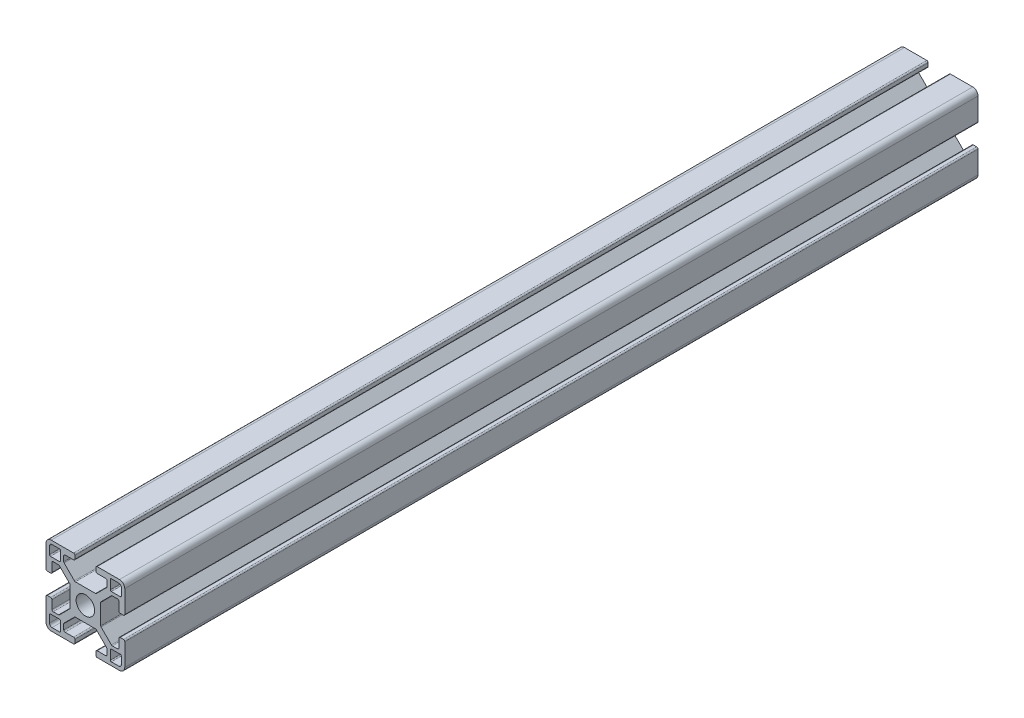
from build123d import *

# Parameters (mm, degrees)
SKETCH1_R           = 3.52998588
BOSS_EXTRUDE1_DEPTH = 162.5


with BuildPart() as part:
    # Sketch1 → Boss-Extrude1 (new body, symmetric)
    with BuildSketch(Plane.XY):
        with BuildLine():
            Line((14.49994, -4), (13.24247465, -4))
            ThreePointArc((13.24247465, -4), (12.88892126, -4.146446609), (12.74247465, -4.5))
            Line((12.74247465, -4.5), (12.74247465, -7.732519321))
            ThreePointArc((12.74247465, -7.732519321), (12.602449697, -8.097296796), (12.242781236, -8.249967))
            Line((12.242781236, -8.249967), (10.260188032, -8.249967))
            ThreePointArc((10.260188032, -8.249967), (10.068847082, -8.211906919), (9.906636056, -8.103520976))
            Line((9.906636056, -8.103520976), (5.981117769, -4.178002689))
            ThreePointArc((5.981117769, -4.178002689), (5.872731827, -4.015791664), (5.834671745, -3.824450713))
            Line((5.834671745, -3.824450713), (5.834671745, -1.01249595))
            Line((5.834671745, -1.01249595), (5.834671745, 0.88749645))
            Line((5.834671745, 0.88749645), (5.834671745, 3.824450713))
            ThreePointArc((5.834671745, 3.824450713), (5.872731827, 4.015791664), (5.981117769, 4.178002689))
            Line((5.981117769, 4.178002689), (9.906636056, 8.103520976))
            ThreePointArc((9.906636056, 8.103520976), (10.068847082, 8.211906919), (10.260188032, 8.249967))
            Line((10.260188032, 8.249967), (12.242781236, 8.249967))
            ThreePointArc((12.242781236, 8.249967), (12.602449697, 8.097296796), (12.74247465, 7.732519321))
            Line((12.74247465, 7.732519321), (12.74247465, 4.5))
            ThreePointArc((12.74247465, 4.5), (12.88892126, 4.146446609), (13.24247465, 4))
            Line((13.24247465, 4), (14.49994, 4))
            ThreePointArc((14.49994, 4), (14.853493391, 4.146446609), (14.99994, 4.5))
            Line((14.99994, 4.5), (14.99994, 12.999948))
            ThreePointArc((14.99994, 12.999948), (14.414155906, 14.414155906), (12.999948, 14.99994))
            Line((12.999948, 14.99994), (4.5, 14.99994))
            ThreePointArc((4.5, 14.99994), (4.146446609, 14.853493391), (4, 14.49994))
            Line((4, 14.49994), (4, 13.24247465))
            ThreePointArc((4, 13.24247465), (4.146446609, 12.88892126), (4.5, 12.74247465))
            Line((4.5, 12.74247465), (7.732519321, 12.74247465))
            ThreePointArc((7.732519321, 12.74247465), (8.097296796, 12.602449697), (8.249967, 12.242781236))
            Line((8.249967, 12.242781236), (8.249967, 10.260188032))
            ThreePointArc((8.249967, 10.260188032), (8.211906919, 10.068847082), (8.103520976, 9.906636056))
            Line((8.103520976, 9.906636056), (4.178002689, 5.981117769))
            ThreePointArc((4.178002689, 5.981117769), (4.015791664, 5.872731827), (3.824450713, 5.834671745))
            Line((3.824450713, 5.834671745), (0.9499962, 5.834671745))
            Line((0.9499962, 5.834671745), (-0.9499962, 5.834671745))
            Line((-0.9499962, 5.834671745), (-3.824450713, 5.834671745))
            ThreePointArc((-3.824450713, 5.834671745), (-4.015791664, 5.872731827), (-4.178002689, 5.981117769))
            Line((-4.178002689, 5.981117769), (-8.103520976, 9.906636056))
            ThreePointArc((-8.103520976, 9.906636056), (-8.211906919, 10.068847082), (-8.249967, 10.260188032))
            Line((-8.249967, 10.260188032), (-8.249967, 12.242781236))
            ThreePointArc((-8.249967, 12.242781236), (-8.097296796, 12.602449697), (-7.732519321, 12.74247465))
            Line((-7.732519321, 12.74247465), (-4.5, 12.74247465))
            ThreePointArc((-4.5, 12.74247465), (-4.146446609, 12.88892126), (-4, 13.24247465))
            Line((-4, 13.24247465), (-4, 14.49994))
            ThreePointArc((-4, 14.49994), (-4.146446609, 14.853493391), (-4.5, 14.99994))
            Line((-4.5, 14.99994), (-12.999948, 14.99994))
            ThreePointArc((-12.999948, 14.99994), (-14.414155906, 14.414155906), (-14.99994, 12.999948))
            Line((-14.99994, 12.999948), (-14.99994, 4.5))
            ThreePointArc((-14.99994, 4.5), (-14.853493391, 4.146446609), (-14.49994, 4))
            Line((-14.49994, 4), (-13.24247465, 4))
            ThreePointArc((-13.24247465, 4), (-12.88892126, 4.146446609), (-12.74247465, 4.5))
            Line((-12.74247465, 4.5), (-12.74247465, 7.732519321))
            ThreePointArc((-12.74247465, 7.732519321), (-12.602449697, 8.097296796), (-12.242781236, 8.249967))
            Line((-12.242781236, 8.249967), (-10.260188032, 8.249967))
            ThreePointArc((-10.260188032, 8.249967), (-10.068847082, 8.211906919), (-9.906636056, 8.103520976))
            Line((-9.906636056, 8.103520976), (-5.981117769, 4.178002689))
            ThreePointArc((-5.981117769, 4.178002689), (-5.872731827, 4.015791664), (-5.834671745, 3.824450713))
            Line((-5.834671745, 3.824450713), (-5.834671745, 0.88749645))
            Line((-5.834671745, 0.88749645), (-5.834671745, -1.01249595))
            Line((-5.834671745, -1.01249595), (-5.834671745, -3.824450713))
            ThreePointArc((-5.834671745, -3.824450713), (-5.872731827, -4.015791664), (-5.981117769, -4.178002689))
            Line((-5.981117769, -4.178002689), (-9.906636056, -8.103520976))
            ThreePointArc((-9.906636056, -8.103520976), (-10.068847082, -8.211906919), (-10.260188032, -8.249967))
            Line((-10.260188032, -8.249967), (-12.242781236, -8.249967))
            ThreePointArc((-12.242781236, -8.249967), (-12.602449697, -8.097296796), (-12.74247465, -7.732519321))
            Line((-12.74247465, -7.732519321), (-12.74247465, -4.5))
            ThreePointArc((-12.74247465, -4.5), (-12.88892126, -4.146446609), (-13.24247465, -4))
            Line((-13.24247465, -4), (-14.49994, -4))
            ThreePointArc((-14.49994, -4), (-14.853493391, -4.146446609), (-14.99994, -4.5))
            Line((-14.99994, -4.5), (-14.99994, -12.999948))
            ThreePointArc((-14.99994, -12.999948), (-14.414155906, -14.414155906), (-12.999948, -14.99994))
            Line((-12.999948, -14.99994), (-4.5, -14.99994))
            ThreePointArc((-4.5, -14.99994), (-4.146446609, -14.853493391), (-4, -14.49994))
            Line((-4, -14.49994), (-4, -13.24247465))
            ThreePointArc((-4, -13.24247465), (-4.146446609, -12.88892126), (-4.5, -12.74247465))
            Line((-4.5, -12.74247465), (-7.732519321, -12.74247465))
            ThreePointArc((-7.732519321, -12.74247465), (-8.097296796, -12.602449697), (-8.249967, -12.242781236))
            Line((-8.249967, -12.242781236), (-8.249967, -10.260188032))
            ThreePointArc((-8.249967, -10.260188032), (-8.211906919, -10.068847082), (-8.103520976, -9.906636056))
            Line((-8.103520976, -9.906636056), (-4.178002689, -5.981117769))
            ThreePointArc((-4.178002689, -5.981117769), (-4.015791664, -5.872731827), (-3.824450713, -5.834671745))
            Line((-3.824450713, -5.834671745), (-0.9499962, -5.834671745))
            Line((-0.9499962, -5.834671745), (0.9499962, -5.834671745))
            Line((0.9499962, -5.834671745), (3.824450713, -5.834671745))
            ThreePointArc((3.824450713, -5.834671745), (4.015791664, -5.872731827), (4.178002689, -5.981117769))
            Line((4.178002689, -5.981117769), (8.103520976, -9.906636056))
            ThreePointArc((8.103520976, -9.906636056), (8.211906919, -10.068847082), (8.249967, -10.260188032))
            Line((8.249967, -10.260188032), (8.249967, -12.242781236))
            ThreePointArc((8.249967, -12.242781236), (8.097296796, -12.602449697), (7.732519321, -12.74247465))
            Line((7.732519321, -12.74247465), (4.5, -12.74247465))
            ThreePointArc((4.5, -12.74247465), (4.146446609, -12.88892126), (4, -13.24247465))
            Line((4, -13.24247465), (4, -14.49994))
            ThreePointArc((4, -14.49994), (4.146446609, -14.853493391), (4.5, -14.99994))
            Line((4.5, -14.99994), (12.999948, -14.99994))
            ThreePointArc((12.999948, -14.99994), (14.414155906, -14.414155906), (14.99994, -12.999948))
            Line((14.99994, -12.999948), (14.99994, -4.5))
            ThreePointArc((14.99994, -4.5), (14.853493391, -4.146446609), (14.49994, -4))
        make_face()
        Circle(SKETCH1_R, mode=Mode.SUBTRACT)
        with BuildLine():
            Line((-12.6999492, -13.6999452), (-9.880960476, -13.6999452))
            ThreePointArc((-9.880960476, -13.6999452), (-9.61155387, -13.58835333), (-9.499962, -13.318946724))
            Line((-9.499962, -13.318946724), (-9.499962, -9.87996048))
            ThreePointArc((-9.499962, -9.87996048), (-9.611260978, -9.611260978), (-9.87996048, -9.499962))
            Line((-9.87996048, -9.499962), (-13.318946724, -9.499962))
            ThreePointArc((-13.318946724, -9.499962), (-13.58835333, -9.61155387), (-13.6999452, -9.880960476))
            Line((-13.6999452, -9.880960476), (-13.6999452, -12.6999492))
            ThreePointArc((-13.6999452, -12.6999492), (-13.407053153, -13.407053153), (-12.6999492, -13.6999452))
        make_face(mode=Mode.SUBTRACT)
        with BuildLine():
            Line((13.6999452, -12.6999492), (13.6999452, -9.880960476))
            ThreePointArc((13.6999452, -9.880960476), (13.58835333, -9.61155387), (13.318946724, -9.499962))
            Line((13.318946724, -9.499962), (9.87996048, -9.499962))
            ThreePointArc((9.87996048, -9.499962), (9.611260978, -9.611260978), (9.499962, -9.87996048))
            Line((9.499962, -9.87996048), (9.499962, -13.318946724))
            ThreePointArc((9.499962, -13.318946724), (9.61155387, -13.58835333), (9.880960476, -13.6999452))
            Line((9.880960476, -13.6999452), (12.6999492, -13.6999452))
            ThreePointArc((12.6999492, -13.6999452), (13.407053153, -13.407053153), (13.6999452, -12.6999492))
        make_face(mode=Mode.SUBTRACT)
        with BuildLine():
            Line((9.87996048, 9.499962), (13.318946724, 9.499962))
            ThreePointArc((13.318946724, 9.499962), (13.58835333, 9.61155387), (13.6999452, 9.880960476))
            Line((13.6999452, 9.880960476), (13.6999452, 12.6999492))
            ThreePointArc((13.6999452, 12.6999492), (13.407053153, 13.407053153), (12.6999492, 13.6999452))
            Line((12.6999492, 13.6999452), (9.880960476, 13.6999452))
            ThreePointArc((9.880960476, 13.6999452), (9.61155387, 13.58835333), (9.499962, 13.318946724))
            Line((9.499962, 13.318946724), (9.499962, 9.87996048))
            ThreePointArc((9.499962, 9.87996048), (9.611260978, 9.611260978), (9.87996048, 9.499962))
        make_face(mode=Mode.SUBTRACT)
        with BuildLine():
            Line((-13.6999452, 12.6999492), (-13.6999452, 9.880960476))
            ThreePointArc((-13.6999452, 9.880960476), (-13.58835333, 9.61155387), (-13.318946724, 9.499962))
            Line((-13.318946724, 9.499962), (-9.87996048, 9.499962))
            ThreePointArc((-9.87996048, 9.499962), (-9.611260978, 9.611260978), (-9.499962, 9.87996048))
            Line((-9.499962, 9.87996048), (-9.499962, 13.318946724))
            ThreePointArc((-9.499962, 13.318946724), (-9.61155387, 13.58835333), (-9.880960476, 13.6999452))
            Line((-9.880960476, 13.6999452), (-12.6999492, 13.6999452))
            ThreePointArc((-12.6999492, 13.6999452), (-13.407053153, 13.407053153), (-13.6999452, 12.6999492))
        make_face(mode=Mode.SUBTRACT)
    extrude(amount=BOSS_EXTRUDE1_DEPTH, both=True)


solid = part.part
